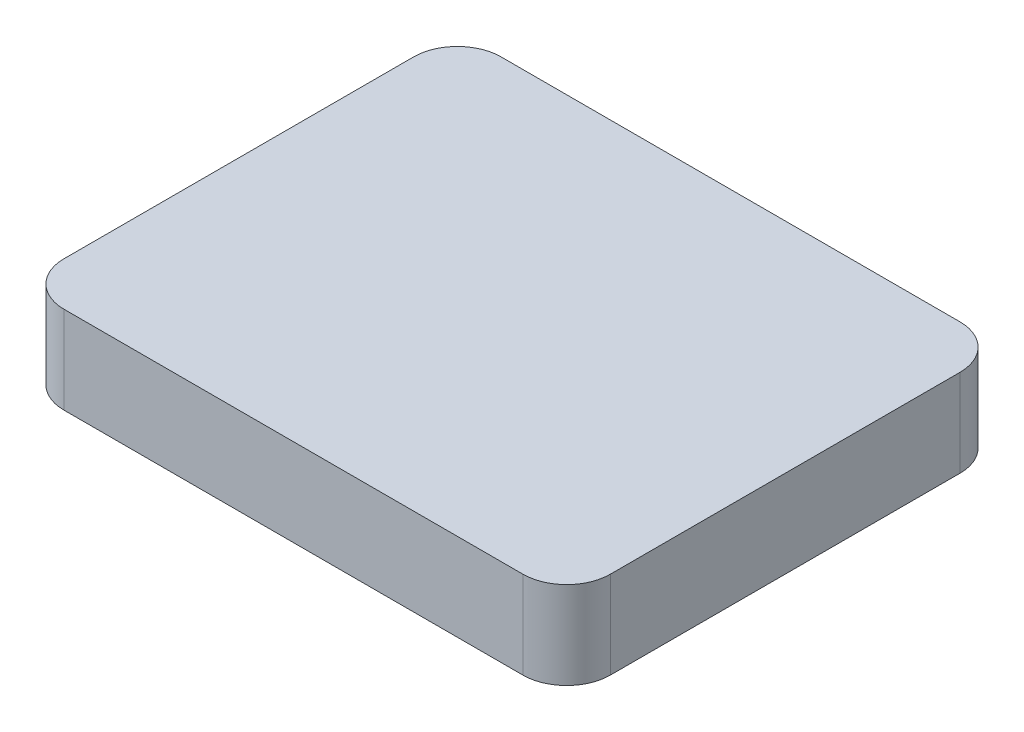
from build123d import *

# Parameters (mm, degrees)
SKETCH1_W           = 250
SKETCH1_H           = 200
BOSS_EXTRUDE1_DEPTH = 40
FILLET1_R           = 20


with BuildPart() as part:
    # Sketch1 → Boss-Extrude1 (new body)
    with BuildSketch(Plane(origin=(0, 0, 0), x_dir=(1, 0, 0), z_dir=(0, 1, 0))):
        Rectangle(SKETCH1_W, SKETCH1_H)
    extrude(amount=BOSS_EXTRUDE1_DEPTH)

    # Fillet1
    fillet1_edges = [part.edges().sort_by_distance(p)[0] for p in [
        (125, 20, 100),
        (-125, 20, 100),
        (-125, 20, -100),
        (125, 20, -100),
    ]]
    fillet(fillet1_edges, radius=FILLET1_R)


solid = part.part
